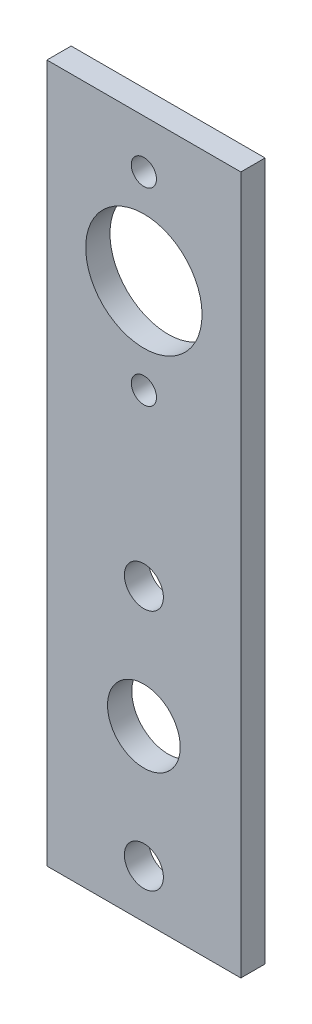
from build123d import *

# Parameters (mm, degrees)
SKETCH1_W           = 25.4
SKETCH1_H           = 91.44
BOSS_EXTRUDE1_DEPTH = 3.175
SKETCH2_R           = 2.5527
SKETCH2_R_2         = 4.7625
CUT_EXTRUDE1_DEPTH  = 3.175
SKETCH3_R           = 1.651
SKETCH3_R_2         = 7.62
CUT_EXTRUDE2_DEPTH  = 3.175


with BuildPart() as part:
    # Sketch1 → Boss-Extrude1 (new body)
    with BuildSketch(Plane.XY):
        with Locations((12.7, 45.72)):
            Rectangle(SKETCH1_W, SKETCH1_H)
    extrude(amount=BOSS_EXTRUDE1_DEPTH)

    # Sketch2 → Cut-Extrude1 (cut)
    with BuildSketch(Plane.XY.offset(3.175)):
        with Locations((12.7, 6.35)):
            Circle(SKETCH2_R)
        with Locations((12.7, 38.1)):
            Circle(SKETCH2_R)
        with Locations((12.7, 22.225)):
            Circle(SKETCH2_R_2)
    extrude(amount=-CUT_EXTRUDE1_DEPTH, mode=Mode.SUBTRACT)

    # Sketch3 → Cut-Extrude2 (cut)
    with BuildSketch(Plane.XY.offset(3.175)):
        with Locations((12.7, 85.09)):
            Circle(SKETCH3_R)
        with Locations((12.7, 60.325)):
            Circle(SKETCH3_R)
        with Locations((12.7, 72.7075)):
            Circle(SKETCH3_R_2)
    extrude(amount=-CUT_EXTRUDE2_DEPTH, mode=Mode.SUBTRACT)


solid = part.part
